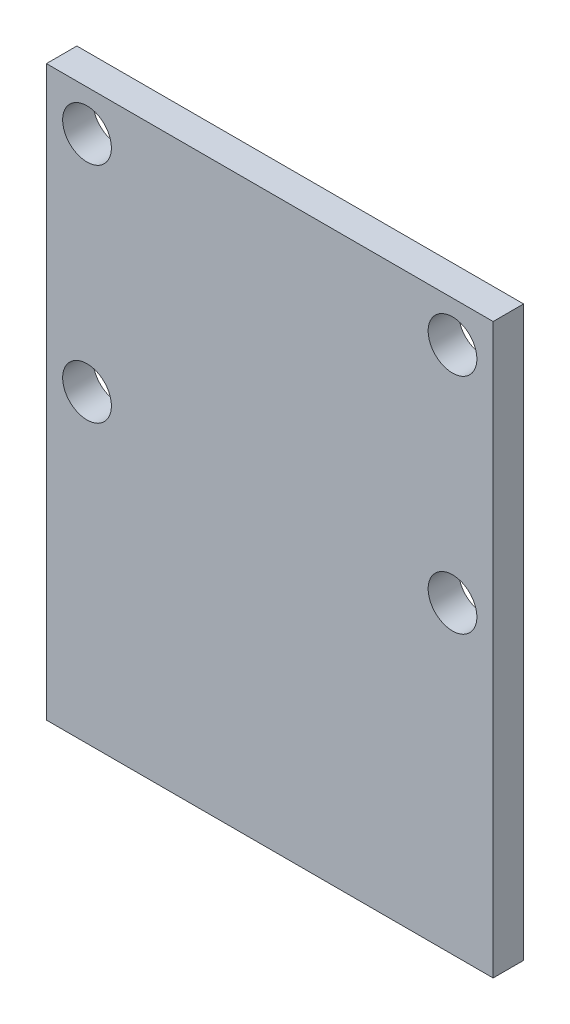
from build123d import *

# Parameters (mm, degrees)
SKETCH_1_W         = 22
SKETCH_1_H         = 28
EXTRUDE_1_DEPTH    = 1.5
HOLE_WIZARD_M2_1_D = 2.4


with BuildPart() as part:
    # ｽｹｯﾁ1 → ﾎﾞｽ - 押し出し1 (new body)
    with BuildSketch(Plane.XY):
        Rectangle(SKETCH_1_W, SKETCH_1_H)
    extrude(amount=EXTRUDE_1_DEPTH)

    # M2 すきま穴1 (through all)
    with Locations(Plane.XY.offset(1.5)):
        with Locations((-9, 12), (9, 12), (-9, 1), (9, 1)):
            Hole(HOLE_WIZARD_M2_1_D / 2)


solid = part.part
